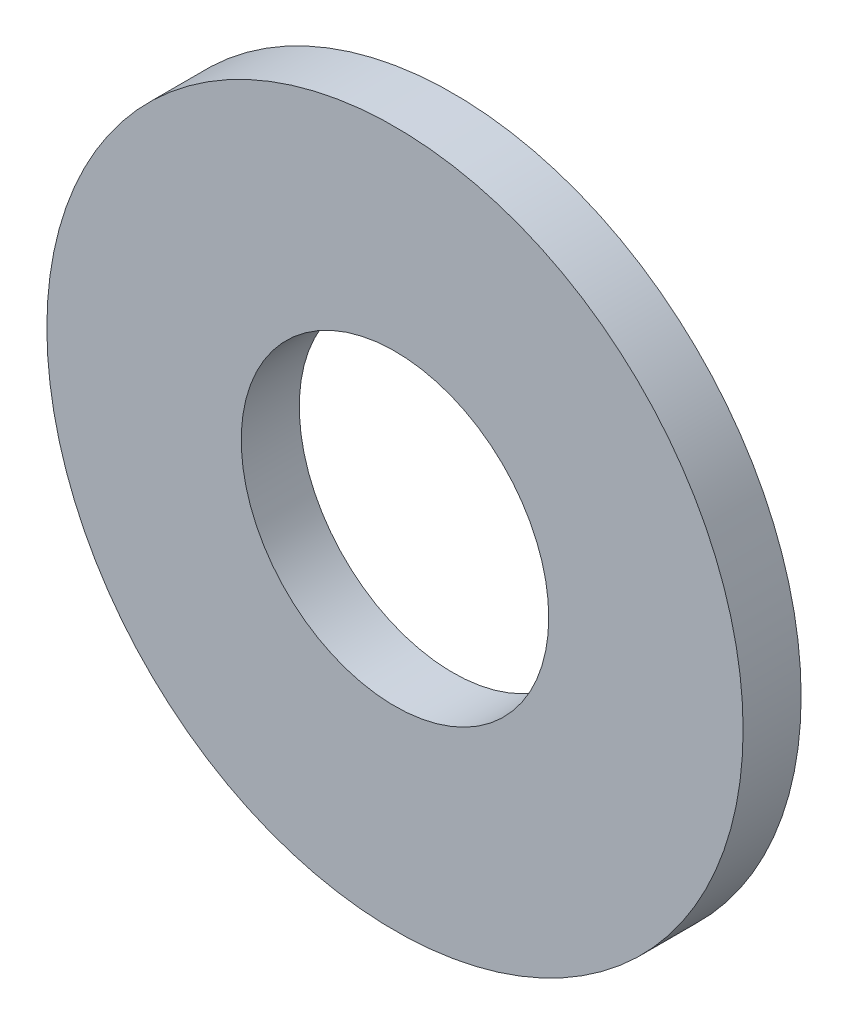
from build123d import *

# Parameters (mm, degrees)
ESQUISSE1_R      = 6
ESQUISSE1_R_2    = 2.65
EXTRUSION1_DEPTH = 1


with BuildPart() as part:
    # Esquisse1 → Extrusion1 (new body)
    with BuildSketch(Plane.XY):
        Circle(ESQUISSE1_R)
        Circle(ESQUISSE1_R_2, mode=Mode.SUBTRACT)
    extrude(amount=EXTRUSION1_DEPTH)


solid = part.part
